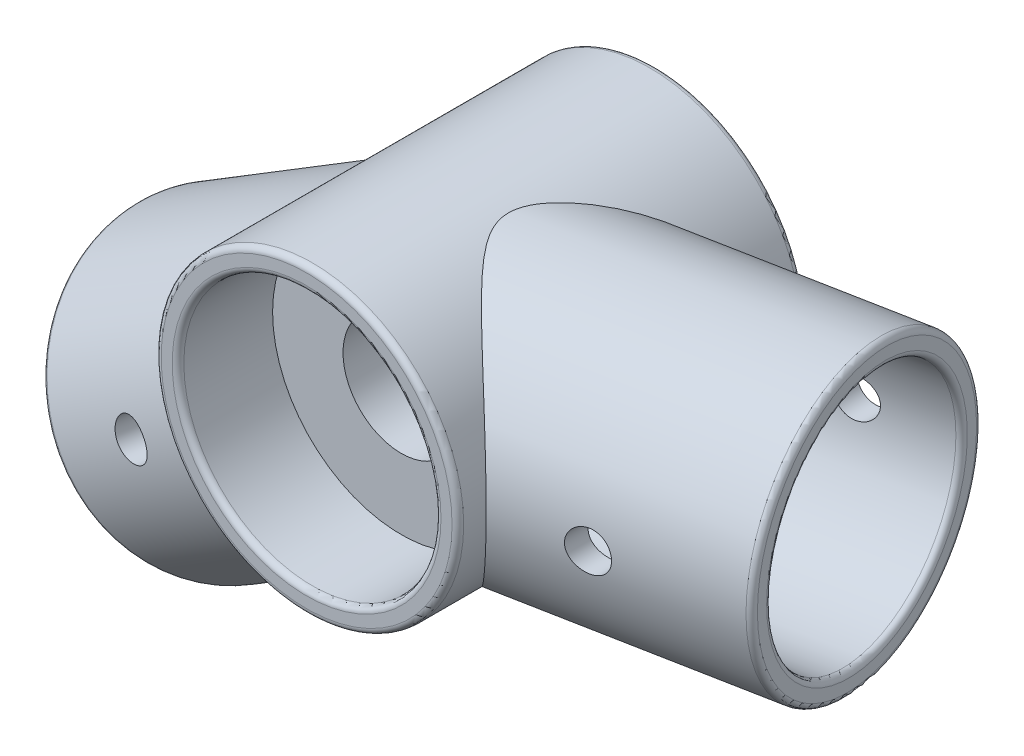
from build123d import *

# Parameters (mm, degrees)
SKETCH2_R               = 13
BOSS_EXTRUDE2_DEPTH     = 15
SKETCH5_R               = 5
CUT_EXTRUDE2_DEPTH      = 31
BOSS_EXTRUDE5_REACH     = 52.035
SKETCH7_R               = 12.35
SKETCH7_R_2             = 10.35
BOSS_EXTRUDE6_REACH     = 66.114
SKETCH9_R               = 12.35
SKETCH9_R_2             = 10.35
SKETCH10_R              = 11.05
CUT_EXTRUDE3_DEPTH      = 8.128
FILLET3_R               = 0.5
FILLET4_R               = 0.5
SKETCH12_R              = 1.7
CUT_EXTRUDE5_DEPTH      = 16.278371511
CUT_EXTRUDE5_DEPTH_BACK = 16
SKETCH15_R              = 1.7
CUT_EXTRUDE6_DEPTH      = 21.271461045
CUT_EXTRUDE6_DEPTH_BACK = 21.630240229


with BuildPart() as part:
    # Sketch2 → Boss-Extrude2 (new body, symmetric)
    with BuildSketch(Plane.XY):
        Circle(SKETCH2_R)
    extrude(amount=BOSS_EXTRUDE2_DEPTH, both=True)

    # Sketch5 → Cut-Extrude2 (cut, through all)
    with BuildSketch(Plane.XY.offset(15)):
        Circle(SKETCH5_R)
    extrude(amount=-CUT_EXTRUDE2_DEPTH, mode=Mode.SUBTRACT)

    # Sketch7 → Boss-Extrude5 (add, up to next)
    with BuildSketch(Plane(origin=(-24.54792956, -16.693219235, 4.328462302), x_dir=(0.116645418, 0.085047727, 0.989525508), z_dir=(-0.818264319, -0.556440641, 0.144282077)), mode=Mode.PRIVATE) as boss_extrude5_sk1:
        with Locations((-1.875660175, 0)):
            Circle(SKETCH7_R)
        with Locations((-1.875660175, 0)):
            Circle(SKETCH7_R_2, mode=Mode.SUBTRACT)
    boss_extrude5_tool1 = extrude(boss_extrude5_sk1.sketch, amount=-BOSS_EXTRUDE5_REACH, mode=Mode.PRIVATE) - part.part
    add(boss_extrude5_tool1.solids().sort_by_distance((-26.166542, -17.873371, -9.402539))[0])

    # Sketch9 → Boss-Extrude6 (add, up to next)
    with BuildSketch(Plane(origin=(29.467341299, 0, 5.62812551), x_dir=(0.187604184, 0, -0.98224471), z_dir=(0.98224471, 0, 0.187604184)), mode=Mode.PRIVATE) as boss_extrude6_sk1:
        with Locations((2.438854388, 0)):
            Circle(SKETCH9_R)
        with Locations((2.438854388, 0)):
            Circle(SKETCH9_R_2, mode=Mode.SUBTRACT)
    boss_extrude6_tool1 = extrude(boss_extrude6_sk1.sketch, amount=-BOSS_EXTRUDE6_REACH, mode=Mode.PRIVATE) - part.part
    add(boss_extrude6_tool1.solids().sort_by_distance((27.673501, 0, 15.020187))[0])

    # Sketch10 → Cut-Extrude3 (cut)
    with BuildSketch(Plane.XY.offset(-15)):
        Circle(SKETCH10_R)
    extrude(amount=CUT_EXTRUDE3_DEPTH, mode=Mode.SUBTRACT)

    # Fillet3
    fillet3_edges = [part.edges().sort_by_distance(p)[0] for p in [
        (-26.207287641, -17.903079294, -9.748191307),
        (-25.973996804, -17.73298384, -7.769140291),
        (27.607968917, 0, 15.363295858),
        (27.983177285, 0, 13.398806438),
    ]]
    fillet(fillet3_edges, radius=FILLET3_R)

    # Fillet4
    fillet4_edges = [part.edges().sort_by_distance(p)[0] for p in [
        (-13, 0, -15),
        (-11.05, 0, -15),
        (-13, 0, 15),
        (-5, 0, 15),
    ]]
    fillet(fillet4_edges, radius=FILLET4_R)

    # Sketch12 → Cut-Extrude5 (cut, two sides)
    with BuildSketch(Plane.XY) as cut_extrude5_sk:
        with Locations((20.350885505, 0)):
            Circle(SKETCH12_R)
    extrude(amount=CUT_EXTRUDE5_DEPTH, mode=Mode.SUBTRACT)
    extrude(cut_extrude5_sk.sketch, amount=-CUT_EXTRUDE5_DEPTH_BACK, mode=Mode.SUBTRACT)

    # Sketch15 → Cut-Extrude6 (cut, two sides)
    with BuildSketch(Plane(origin=(0, 0, 0), x_dir=(0, -1, 0), z_dir=(-0.173648178, 0, -0.984807753))) as cut_extrude6_sk:
        with Locations((11.430714778, 16.830601402)):
            Circle(SKETCH15_R)
    extrude(amount=CUT_EXTRUDE6_DEPTH, mode=Mode.SUBTRACT)
    extrude(cut_extrude6_sk.sketch, amount=-CUT_EXTRUDE6_DEPTH_BACK, mode=Mode.SUBTRACT)


with BuildPart() as body_2:
    # Mirror3: mirrored copy
    add(part.part.mirror(Plane.XY.offset(-20)))


solid = body_2.part
